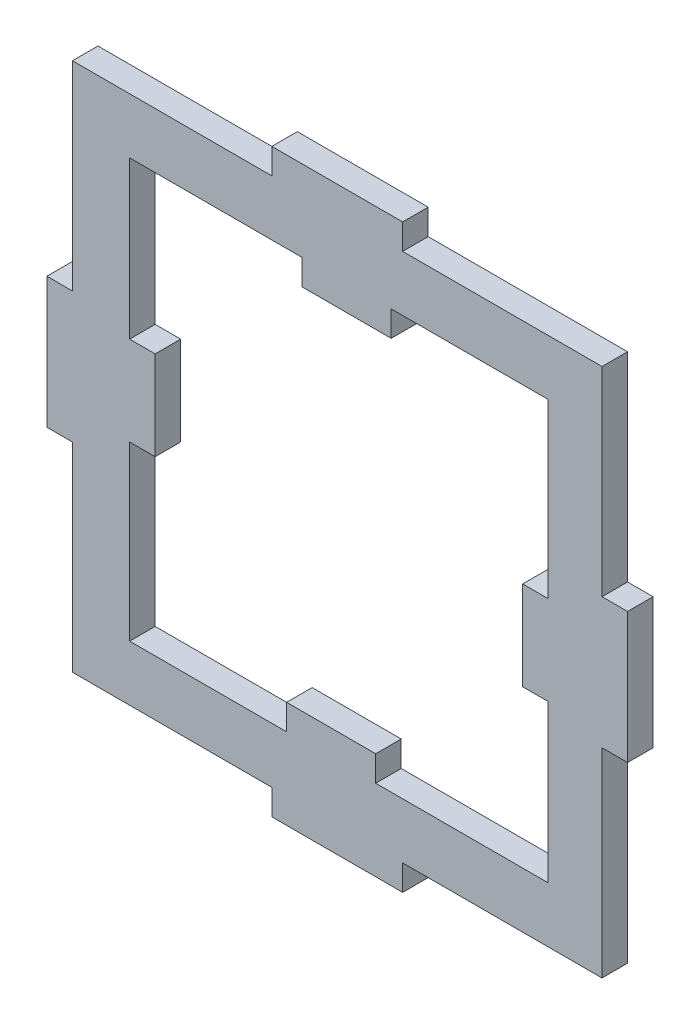
from build123d import *

# Parameters (mm, degrees)
BOSS_EXTRUDE1_DEPTH = 4.6
CUT_EXTRUDE1_DEPTH  = 5.6


with BuildPart() as part:
    # Sketch1 → Boss-Extrude1 (new body)
    with BuildSketch(Plane.XY):
        Polygon((47.4, 11.783577493), (52, 11.783577493), (52, -11.783577493), (47.4, -11.783577493), (47.4, -47.7), (11.483577493, -47.7), (11.483577493, -52.3), (-12.083577493, -52.3), (-12.083577493, -47.7), (-48, -47.7), (-48, -11.783577493), (-52.6, -11.783577493), (-52.6, 11.783577493), (-48, 11.783577493), (-48, 47.7), (-12.083577493, 47.7), (-12.083577493, 52.3), (11.483577493, 52.3), (11.483577493, 47.7), (47.4, 47.7), align=None)
    extrude(amount=BOSS_EXTRUDE1_DEPTH)

    # Sketch2 → Cut-Extrude1 (cut, through all)
    with BuildSketch(Plane(origin=(0, 0, 0), x_dir=(-1, 0, 0), z_dir=(0, 0, -1))):
        Polygon((9.417835971, -37.7), (9.417835971, -33.1), (-6.62560911, -33.1), (-6.62560911, -37.7), (-37.7, -37.7), (-37.7, -9.417835971), (-33.1, -9.417835971), (-33.1, 6.62560911), (-37.7, 6.62560911), (-37.7, 37.7), (-9.417835971, 37.7), (-9.417835971, 33.1), (6.62560911, 33.1), (6.62560911, 37.7), (37.7, 37.7), (37.7, 9.417835971), (33.1, 9.417835971), (33.1, -6.62560911), (37.7, -6.62560911), (37.7, -37.7), align=None)
    extrude(amount=-CUT_EXTRUDE1_DEPTH, mode=Mode.SUBTRACT)


solid = part.part
